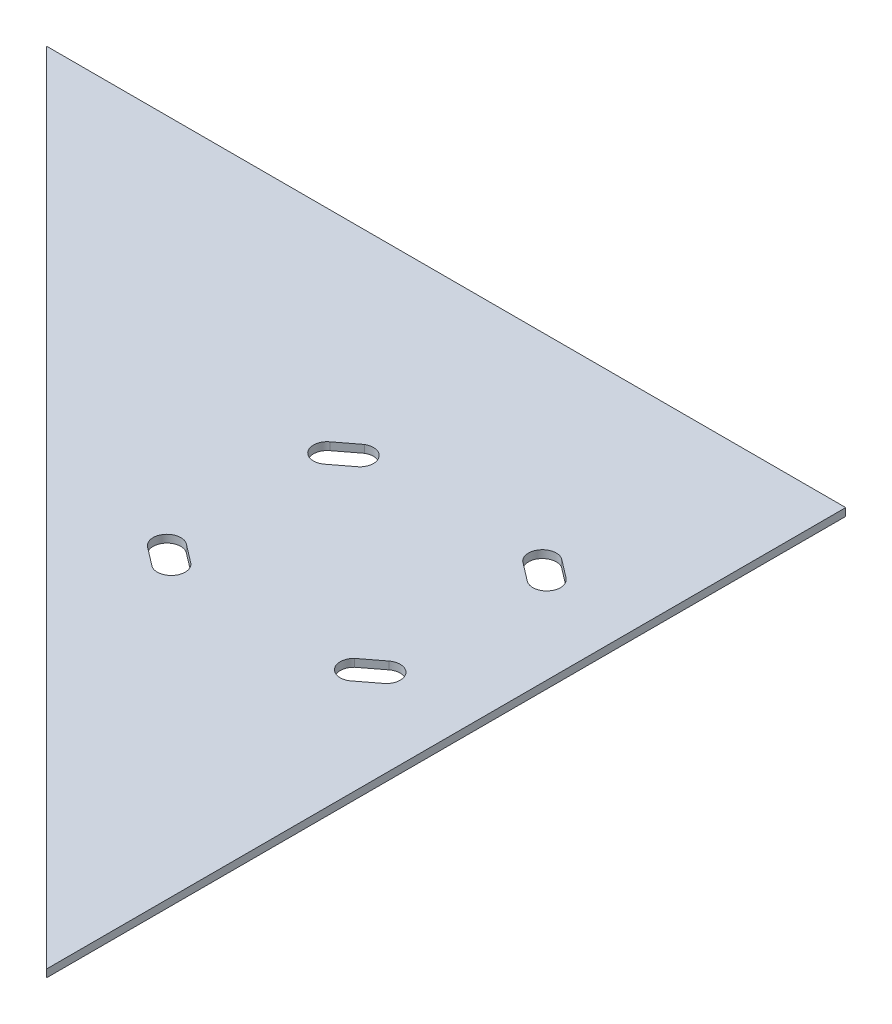
from build123d import *

# Parameters (mm, degrees)
BOSS_EXTRUDE1_DEPTH = 3.175


with BuildPart() as part:
    # Sketch1 → Boss-Extrude1 (new body)
    with BuildSketch(Plane(origin=(0, 0, 0), x_dir=(1, 0, 0), z_dir=(0, 1, 0))):
        Polygon((81.28, -209.55), (81.28, 120.65), (-248.92, 120.65), align=None)
        with BuildLine():
            Line((-48.781915156, 37.648908469), (-40.711239573, 43.820601562))
            ThreePointArc((-40.711239573, 43.820601562), (-33.204324417, 42.366693093), (-33.768084844, 34.741091531))
            Line((-33.768084844, 34.741091531), (-41.838760427, 28.569398438))
            ThreePointArc((-41.838760427, 28.569398438), (-49.850092807, 29.637576089), (-48.781915156, 37.648908469))
        make_face(mode=Mode.SUBTRACT)
        with BuildLine():
            Line((33.768084844, 34.741091531), (41.838760427, 28.569398438))
            ThreePointArc((41.838760427, 28.569398438), (49.850092807, 29.637576089), (48.781915156, 37.648908469))
            Line((48.781915156, 37.648908469), (40.711239573, 43.820601562))
            ThreePointArc((40.711239573, 43.820601562), (33.204324417, 42.366693093), (33.768084844, 34.741091531))
        make_face(mode=Mode.SUBTRACT)
        with BuildLine():
            Line((33.768084844, -34.741091531), (41.838760427, -28.569398438))
            ThreePointArc((41.838760427, -28.569398438), (49.850092807, -29.637576089), (48.781915156, -37.648908469))
            Line((48.781915156, -37.648908469), (40.711239573, -43.820601562))
            ThreePointArc((40.711239573, -43.820601562), (33.204324417, -42.366693093), (33.768084844, -34.741091531))
        make_face(mode=Mode.SUBTRACT)
        with BuildLine():
            Line((-48.781915156, -37.648908469), (-40.711239573, -43.820601562))
            ThreePointArc((-40.711239573, -43.820601562), (-33.204324417, -42.366693093), (-33.768084844, -34.741091531))
            Line((-33.768084844, -34.741091531), (-41.838760427, -28.569398438))
            ThreePointArc((-41.838760427, -28.569398438), (-49.850092807, -29.637576089), (-48.781915156, -37.648908469))
        make_face(mode=Mode.SUBTRACT)
    extrude(amount=BOSS_EXTRUDE1_DEPTH)


solid = part.part
